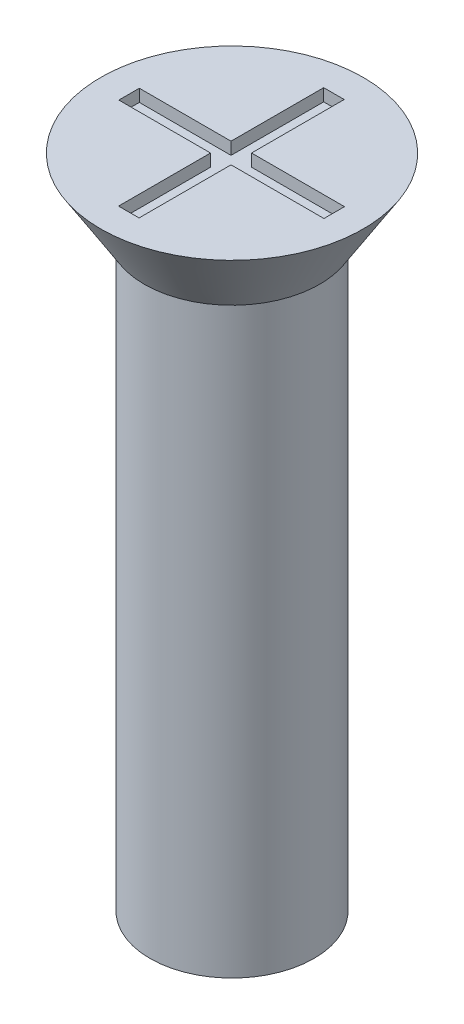
from build123d import *

# Parameters (mm, degrees)
SKETCH1_R           = 2
BOSS_EXTRUDE1_DEPTH = 16
SKETCH2_R           = 3.2
BOSS_EXTRUDE2_DEPTH = 1.7
BOSS_EXTRUDE2_TAPER = 32
SKETCH3_W           = 0.5
SKETCH3_H           = 2.258378485
SKETCH3_H_2         = 2.241621515
SKETCH3_W_2         = 2.234727157
SKETCH3_H_3         = 0.5
SKETCH3_W_3         = 2.265272843
CUT_EXTRUDE1_DEPTH  = 0.3


with BuildPart() as part:
    # Sketch1 → Boss-Extrude1 (new body)
    with BuildSketch(Plane(origin=(0, 0, 0), x_dir=(1, 0, 0), z_dir=(0, 1, 0))):
        Circle(SKETCH1_R)
    extrude(amount=BOSS_EXTRUDE1_DEPTH)

    # Sketch2 → Boss-Extrude2 (add)
    with BuildSketch(Plane(origin=(0, 16, 0), x_dir=(1, 0, 0), z_dir=(0, 1, 0))):
        Circle(SKETCH2_R)
    extrude(amount=-BOSS_EXTRUDE2_DEPTH, taper=BOSS_EXTRUDE2_TAPER)

    # Sketch3 → Cut-Extrude1 (cut)
    with BuildSketch(Plane(origin=(0, 16, 0), x_dir=(1, 0, 0), z_dir=(0, 1, 0))):
        with Locations((-0.015272843, 1.370810757)):
            Rectangle(SKETCH3_W, SKETCH3_H)
        with Locations((-0.015272843, -1.379189243)):
            Rectangle(SKETCH3_W, SKETCH3_H_2)
        with Locations((-1.382636421, -0.008378485)):
            Rectangle(SKETCH3_W_2, SKETCH3_H_3)
        with Locations((1.367363579, -0.008378485)):
            Rectangle(SKETCH3_W_3, SKETCH3_H_3)
        with Locations((-0.015272843, -0.008378485)):
            Rectangle(SKETCH3_W, SKETCH3_H_3)
    extrude(amount=-CUT_EXTRUDE1_DEPTH, mode=Mode.SUBTRACT)


solid = part.part
